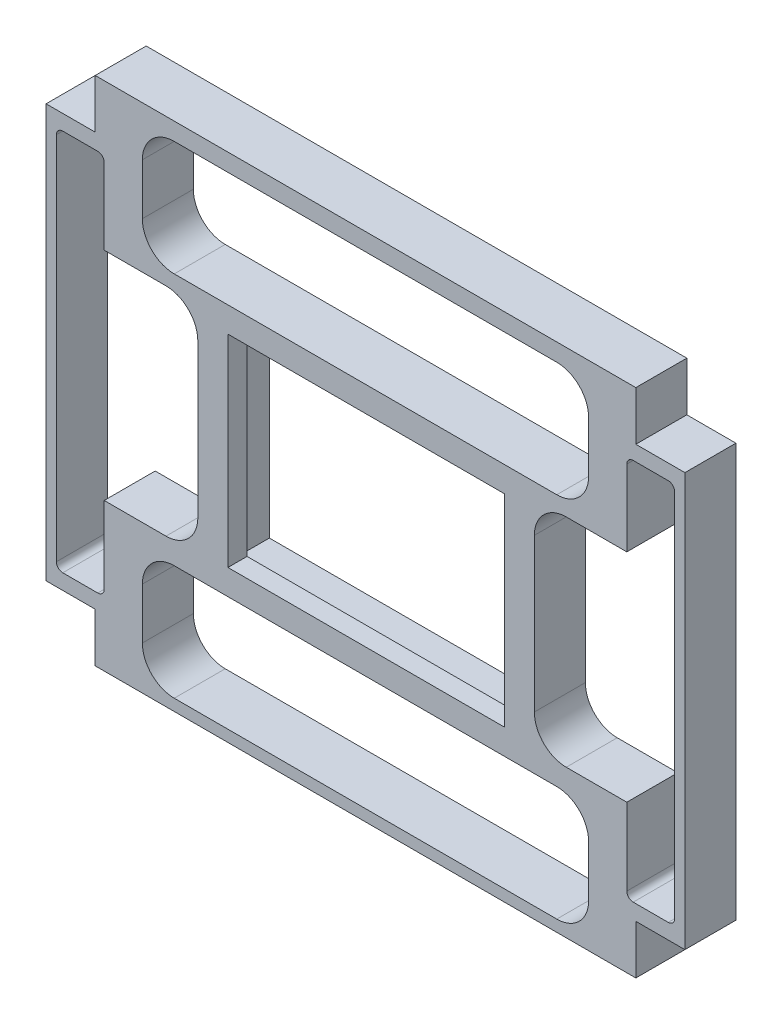
from build123d import *

# Parameters (mm, degrees)
ESQUISSE1_W             = 46.15
ESQUISSE1_H             = 34.15
BOSS_EXTRU_1_DEPTH      = 5
BOSS_EXTRU_2_DEPTH      = 3
ENL_V_MAT_EXTRU_4_DEPTH = 9
ESQUISSE7_W             = 43.35
ESQUISSE7_H             = 31.7
ENL_V_MAT_EXTRU_5_DEPTH = 7
ENL_V_MAT_EXTRU_6_DEPTH = 9


with BuildPart() as part:
    # Esquisse1 → Boss.-Extru.1 (new body)
    with BuildSketch(Plane.XY):
        Polygon((-40.258600608, 39.883341456), (44.541399392, 39.883341456), (44.541399392, 32.183341456), (52.241399392, 32.183341456), (52.241399392, -32.616658544), (44.541399392, -32.616658544), (44.541399392, -40.316658544), (-40.258600608, -40.316658544), (-40.258600608, -32.616658544), (-47.958600608, -32.616658544), (-47.958600608, 32.183341456), (-40.258600608, 32.183341456), align=None)
        with Locations((2.141399392, -0.216658544)):
            Rectangle(ESQUISSE1_W, ESQUISSE1_H, mode=Mode.SUBTRACT)
    extrude(amount=BOSS_EXTRU_1_DEPTH)

    # Esquisse2 → Boss.-Extru.2 (add)
    with BuildSketch(Plane.XY.offset(5)):
        Polygon((-47.958600608, 32.183341456), (-40.258600608, 32.183341456), (-40.258600608, 39.883341456), (44.541399392, 39.883341456), (44.541399392, 32.183341456), (52.241399392, 32.183341456), (52.241399392, -32.616658544), (44.541399392, -32.616658544), (44.541399392, -40.316658544), (-40.258600608, -40.316658544), (-40.258600608, -32.616658544), (-47.958600608, -32.616658544), align=None)
    extrude(amount=BOSS_EXTRU_2_DEPTH)

    # Esquisse6 → Enlèv. mat.-Extru.4 (cut, through all)
    with BuildSketch(Plane(origin=(0, 0, 0), x_dir=(-1, 0, 0), z_dir=(0, 0, -1))):
        with BuildLine():
            Line((-49.628899392, 29.783341456), (-44.128899392, 29.783341456))
            ThreePointArc((-44.128899392, 29.783341456), (-43.421792611, 29.490448238), (-43.128899392, 28.783341456))
            Line((-43.128899392, 28.783341456), (-43.128899392, -29.216658544))
            ThreePointArc((-43.128899392, -29.216658544), (-43.421792611, -29.923765325), (-44.128899392, -30.216658544))
            Line((-44.128899392, -30.216658544), (-49.628899392, -30.216658544))
            ThreePointArc((-49.628899392, -30.216658544), (-50.336006173, -29.923765325), (-50.628899392, -29.216658544))
            Line((-50.628899392, -29.216658544), (-50.628899392, 28.783341456))
            ThreePointArc((-50.628899392, 28.783341456), (-50.336006173, 29.490448238), (-49.628899392, 29.783341456))
        make_face()
        with BuildLine():
            Line((45.346100608, -30.216658544), (39.846100608, -30.216658544))
            ThreePointArc((39.846100608, -30.216658544), (39.138993827, -29.923765325), (38.846100608, -29.216658544))
            Line((38.846100608, -29.216658544), (38.846100608, 28.783341456))
            ThreePointArc((38.846100608, 28.783341456), (39.138993827, 29.490448238), (39.846100608, 29.783341456))
            Line((39.846100608, 29.783341456), (45.346100608, 29.783341456))
            ThreePointArc((45.346100608, 29.783341456), (46.053207389, 29.490448238), (46.346100608, 28.783341456))
            Line((46.346100608, 28.783341456), (46.346100608, -29.216658544))
            ThreePointArc((46.346100608, -29.216658544), (46.053207389, -29.923765325), (45.346100608, -30.216658544))
        make_face()
    extrude(amount=-ENL_V_MAT_EXTRU_4_DEPTH, mode=Mode.SUBTRACT)

    # Esquisse7 → Enlèv. mat.-Extru.5 (cut)
    with BuildSketch(Plane(origin=(0, 0, 5), x_dir=(-1, 0, 0), z_dir=(0, 0, -1))):
        with Locations((-2.236399392, -0.691658544)):
            Rectangle(ESQUISSE7_W, ESQUISSE7_H)
    extrude(amount=-ENL_V_MAT_EXTRU_5_DEPTH, mode=Mode.SUBTRACT)

    # Esquisse8 → Enlèv. mat.-Extru.6 (cut, through all)
    with BuildSketch(Plane(origin=(0, 0, 0), x_dir=(-1, 0, 0), z_dir=(0, 0, -1))):
        with BuildLine():
            Line((-32.141399392, 37.127856995), (27.858600608, 37.127856995))
            ThreePointArc((27.858600608, 37.127856995), (31.394134514, 35.663390901), (32.858600608, 32.127856995))
            Line((32.858600608, 32.127856995), (32.858600608, 24.127856995))
            ThreePointArc((32.858600608, 24.127856995), (31.394134514, 20.592323089), (27.858600608, 19.127856995))
            Line((27.858600608, 19.127856995), (-32.141399392, 19.127856995))
            ThreePointArc((-32.141399392, 19.127856995), (-35.676933298, 20.592323089), (-37.141399392, 24.127856995))
            Line((-37.141399392, 24.127856995), (-37.141399392, 32.127856995))
            ThreePointArc((-37.141399392, 32.127856995), (-35.676933298, 35.663390901), (-32.141399392, 37.127856995))
        make_face()
        with BuildLine():
            Line((-32.141399392, -20.511174082), (27.858600608, -20.511174082))
            ThreePointArc((27.858600608, -20.511174082), (31.394134514, -21.975640176), (32.858600608, -25.511174082))
            Line((32.858600608, -25.511174082), (32.858600608, -33.511174082))
            ThreePointArc((32.858600608, -33.511174082), (31.394134514, -37.046707988), (27.858600608, -38.511174082))
            Line((27.858600608, -38.511174082), (-32.141399392, -38.511174082))
            ThreePointArc((-32.141399392, -38.511174082), (-35.676933298, -37.046707988), (-37.141399392, -33.511174082))
            Line((-37.141399392, -33.511174082), (-37.141399392, -25.511174082))
            ThreePointArc((-37.141399392, -25.511174082), (-35.676933298, -21.975640176), (-32.141399392, -20.511174082))
        make_face()
        with BuildLine():
            Line((-43.128899392, 16.858341456), (-33.628899392, 16.858341456))
            ThreePointArc((-33.628899392, 16.858341456), (-30.093365486, 15.393875362), (-28.628899392, 11.858341456))
            Line((-28.628899392, 11.858341456), (-28.628899392, -12.141658544))
            ThreePointArc((-28.628899392, -12.141658544), (-30.093365486, -15.677192449), (-33.628899392, -17.141658544))
            Line((-33.628899392, -17.141658544), (-45.647019221, -17.141658544))
            Line((-45.647019221, -17.141658544), (-45.647019221, 16.858341456))
            Line((-45.647019221, 16.858341456), (-43.128899392, 16.858341456))
        make_face()
        with BuildLine():
            Line((41.174220437, -17.141658544), (41.174220437, 16.858341456))
            Line((41.174220437, 16.858341456), (38.656100608, 16.858341456))
            Line((38.656100608, 16.858341456), (29.156100608, 16.858341456))
            ThreePointArc((29.156100608, 16.858341456), (25.620566702, 15.393875362), (24.156100608, 11.858341456))
            Line((24.156100608, 11.858341456), (24.156100608, -12.141658544))
            ThreePointArc((24.156100608, -12.141658544), (25.620566702, -15.677192449), (29.156100608, -17.141658544))
            Line((29.156100608, -17.141658544), (41.174220437, -17.141658544))
        make_face()
    extrude(amount=-ENL_V_MAT_EXTRU_6_DEPTH, mode=Mode.SUBTRACT)


solid = part.part
